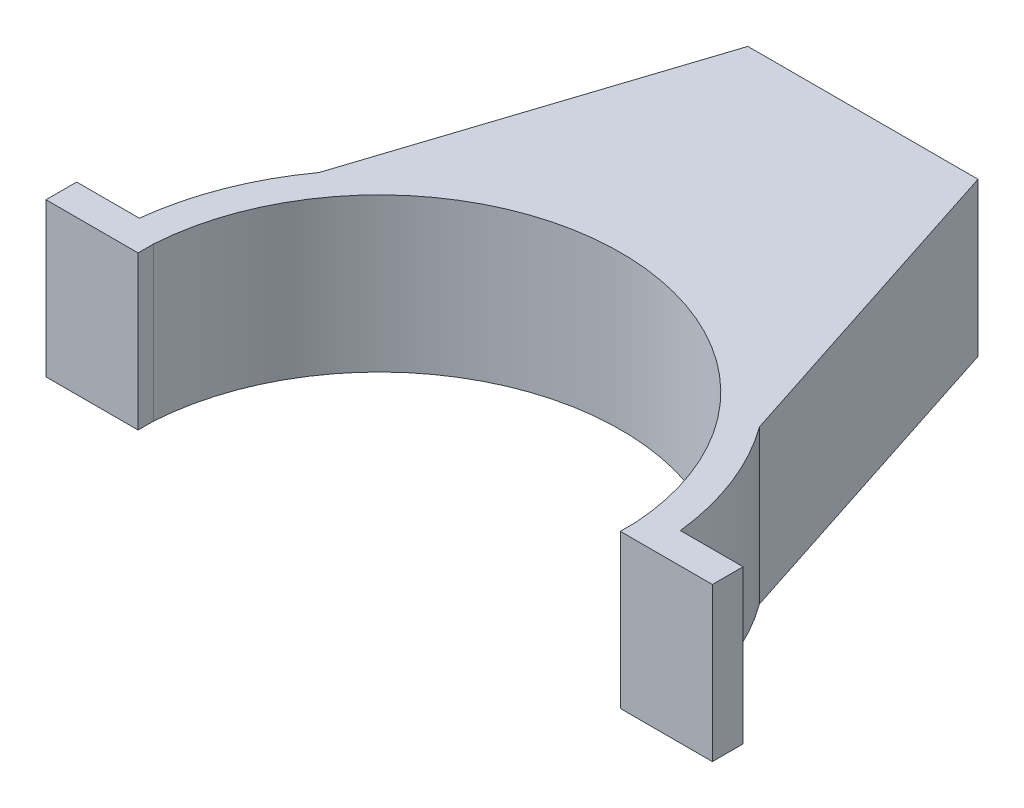
from build123d import *

# Parameters (mm, degrees)
SKETCH1_R               = 45.0723
SKETCH1_R_2             = 39.9923
BOSS_EXTRUDE1_DEPTH     = 25.4
BOSS_EXTRUDE2_DEPTH     = 12.7
BOSS_EXTRUDE3_DEPTH     = 12.7
SKETCH4_W               = 90.1446
SKETCH4_H               = 25.4
CUT_EXTRUDE1_DEPTH      = 46.0723
CUT_EXTRUDE1_DEPTH_BACK = 2.54
BOSS_EXTRUDE4_DEPTH     = 2.54


with BuildPart() as part:
    # Sketch1 → Boss-Extrude1 (new body)
    with BuildSketch(Plane(origin=(0, 0, 0), x_dir=(1, 0, 0), z_dir=(0, 1, 0))):
        Circle(SKETCH1_R)
        Circle(SKETCH1_R_2, mode=Mode.SUBTRACT)
    extrude(amount=BOSS_EXTRUDE1_DEPTH)

    # Sketch2 → Boss-Extrude2 (add, symmetric)
    with BuildSketch(Plane(origin=(0, 12.7, 0), x_dir=(1, 0, 0), z_dir=(0, 1, 0))):
        Polygon((45.0723, 0), (19.05, 80.085348852), (-19.05, 80.085348852), (-45.0723, 0), (-42.65662525, -0.784930252), (-17.204603736, 77.545348852), (17.204603736, 77.545348852), (42.65662525, -0.784930252), align=None)
    extrude(amount=BOSS_EXTRUDE2_DEPTH, both=True)

    # Sketch3 → Boss-Extrude3 (add)
    with BuildSketch(Plane(origin=(0, 25.4, 0), x_dir=(1, 0, 0), z_dir=(0, 1, 0))):
        with BuildLine():
            Line((-17.204603736, 77.545348852), (17.204603736, 77.545348852))
            Line((17.204603736, 77.545348852), (32.130834652, 31.60888628))
            ThreePointArc((32.130834652, 31.60888628), (0, 45.0723), (-32.130834652, 31.60888628))
            Line((-32.130834652, 31.60888628), (-17.204603736, 77.545348852))
        make_face()
    extrude(amount=-BOSS_EXTRUDE3_DEPTH)

    # Sketch4 → Cut-Extrude1 (cut, two sides)
    with BuildSketch(Plane.XY) as cut_extrude1_sk:
        with Locations((0, 12.7)):
            Rectangle(SKETCH4_W, SKETCH4_H)
    extrude(amount=CUT_EXTRUDE1_DEPTH, mode=Mode.SUBTRACT)
    extrude(cut_extrude1_sk.sketch, amount=-CUT_EXTRUDE1_DEPTH_BACK, mode=Mode.SUBTRACT)

    # Sketch5 → Boss-Extrude4 (add, symmetric)
    with BuildSketch(Plane.XY.offset(-2.54)):
        Polygon((-45.000673632, 25.4), (-39.911557966, 25.4), (-39.911557966, 0), (-45.086454025, 0), (-55.160673632, 0), (-55.160673632, 25.4), align=None)
        Polygon((55.160673632, 25.4), (55.160673632, 0), (45.086454025, 0), (39.911557966, 0), (39.911557966, 25.4), (45.000673632, 25.4), align=None)
    extrude(amount=BOSS_EXTRUDE4_DEPTH, both=True)


solid = part.part
